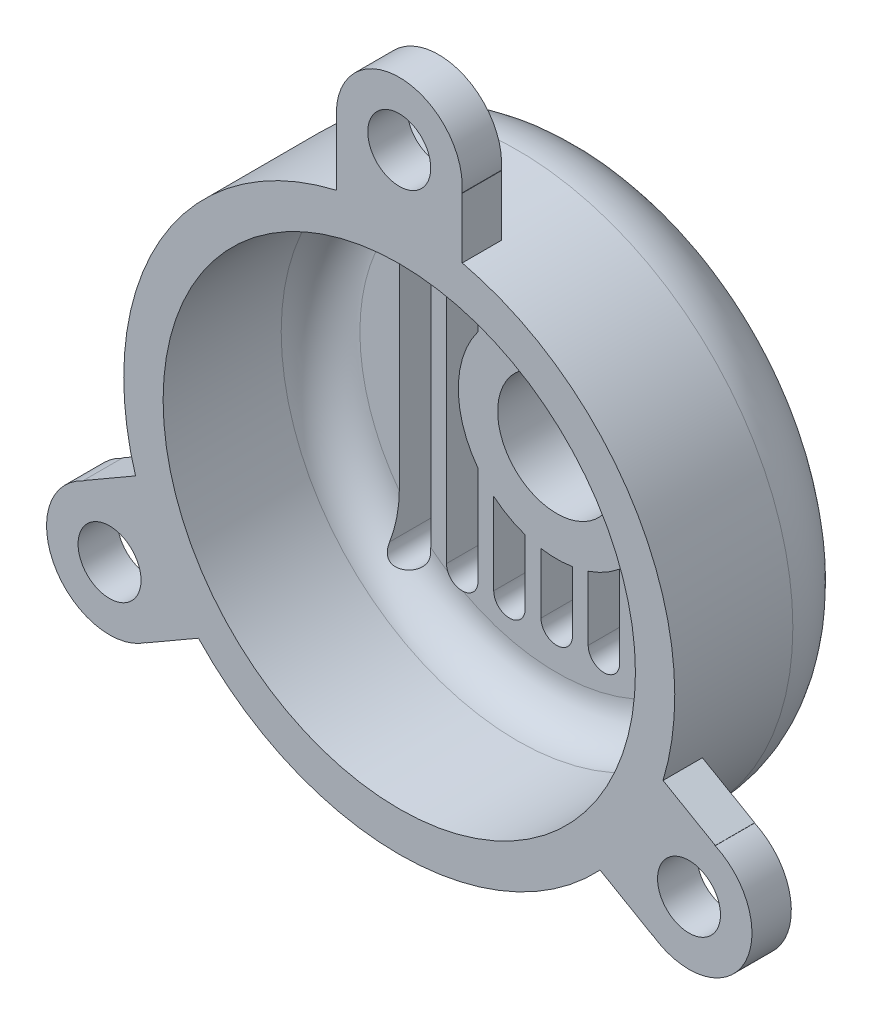
from build123d import *

# Parameters (mm, degrees)
SKETCH3_R           = 4
BOSS_EXTRUDE1_DEPTH = 5
CUT_EXTRUDE1_DEPTH  = 80
SKETCH8_R           = 12.5
SKETCH8_R_2         = 7.5
BOSS_EXTRUDE2_DEPTH = 10
FILLET1_R           = 2
SKETCH9_R           = 7.5
CUT_EXTRUDE2_DEPTH  = 46


with BuildPart() as part:
    # Sketch1 → Revolve1 (revolve)
    with BuildSketch(Plane(origin=(0, 0, 0), x_dir=(1, 0, 0), z_dir=(0, 1, 0)), mode=Mode.PRIVATE) as revolve1_sk:
        with BuildLine():
            Line((0, -5), (25, -5))
            ThreePointArc((25, -5), (28.535533906, -6.464466094), (30, -10))
            Line((30, -10), (30, -25))
            Line((30, -25), (35, -25))
            Line((35, -25), (35, -10))
            ThreePointArc((35, -10), (32.071067812, -2.928932188), (25, 0))
            Line((25, 0), (0, 0))
            Line((0, 0), (0, -5))
        make_face()
    revolve(revolve1_sk.sketch.rotate(Axis((0, 0, -16.961133808), (0, 0, 1)), 180), axis=Axis((0, 0, -16.961133808), (0, 0, 1)))

    # Sketch3 → Boss-Extrude1 (add)
    with BuildSketch(Plane.XY.offset(25)):
        with BuildLine():
            ThreePointArc((-8, 34.073450075), (0, 35), (8, 34.073450075))
            Line((8, 34.073450075), (8, 41.740268327))
            ThreePointArc((8, 41.740268327), (7.982245051, 41.743667351), (7.964488658, 41.747058824))
            ThreePointArc((7.964488658, 41.747058824), (7.991117233, 42.123110935), (8, 42.5))
            ThreePointArc((8, 42.5), (0, 50.5), (-8, 42.5))
            ThreePointArc((-8, 42.5), (-7.991117233, 42.123110935), (-7.964488658, 41.747058824))
            ThreePointArc((-7.964488658, 41.747058824), (-7.982245051, 41.743667351), (-8, 41.740268327))
            Line((-8, 41.740268327), (-8, 34.073450075))
        make_face()
        with Locations((0, 42.5)):
            Circle(SKETCH3_R, mode=Mode.SUBTRACT)
        with BuildLine():
            Line((-32.148132732, -27.798337394), (-25.508473359, -23.964928268))
            ThreePointArc((-25.508473359, -23.964928268), (-30.310889132, -17.5), (-33.508473359, -10.108521807))
            Line((-33.508473359, -10.108521807), (-40.148132732, -13.941930933))
            ThreePointArc((-40.148132732, -13.941930933), (-40.142198899, -13.959006682), (-40.136257804, -13.976079906))
            ThreePointArc((-40.136257804, -13.976079906), (-40.475242772, -14.141044939), (-40.806079661, -14.32179677))
            ThreePointArc((-40.806079661, -14.32179677), (-43.734282891, -25.25), (-32.806079661, -28.17820323))
            ThreePointArc((-32.806079661, -28.17820323), (-32.484125539, -27.982065996), (-32.171769145, -27.770978918))
            ThreePointArc((-32.171769145, -27.770978918), (-32.159953848, -27.784660669), (-32.148132732, -27.798337394))
        make_face()
        with Locations((-36.806079661, -21.25)):
            Circle(SKETCH3_R, mode=Mode.SUBTRACT)
        with BuildLine():
            ThreePointArc((32.806079661, -28.17820323), (43.734282891, -25.25), (40.806079661, -14.32179677))
            ThreePointArc((40.806079661, -14.32179677), (40.475242772, -14.141044939), (40.136257804, -13.976079906))
            ThreePointArc((40.136257804, -13.976079906), (40.142198899, -13.959006682), (40.148132732, -13.941930933))
            Line((40.148132732, -13.941930933), (33.508473359, -10.108521807))
            ThreePointArc((33.508473359, -10.108521807), (30.310889132, -17.5), (25.508473359, -23.964928268))
            Line((25.508473359, -23.964928268), (32.148132732, -27.798337394))
            ThreePointArc((32.148132732, -27.798337394), (32.159953848, -27.784660669), (32.171769145, -27.770978918))
            ThreePointArc((32.171769145, -27.770978918), (32.484125539, -27.982065996), (32.806079661, -28.17820323))
        make_face()
        with Locations((36.806079661, -21.25)):
            Circle(SKETCH3_R, mode=Mode.SUBTRACT)
    extrude(amount=-BOSS_EXTRUDE1_DEPTH)

    # Sketch5 → Cut-Extrude1 (cut)
    with BuildSketch(Plane.XY):
        with BuildLine():
            Line((2, 20), (2, -20))
            ThreePointArc((2, -20), (0, -22), (-2, -20))
            Line((-2, -20), (-2, 20))
            ThreePointArc((-2, 20), (0, 22), (2, 20))
        make_face()
        with BuildLine():
            Line((8, 20), (8, -20))
            ThreePointArc((8, -20), (6, -22), (4, -20))
            Line((4, -20), (4, 20))
            ThreePointArc((4, 20), (6, 22), (8, 20))
        make_face()
        with BuildLine():
            Line((14, 20), (14, -20))
            ThreePointArc((14, -20), (12, -22), (10, -20))
            Line((10, -20), (10, 20))
            ThreePointArc((10, 20), (12, 22), (14, 20))
        make_face()
        with BuildLine():
            Line((20, 20), (20, -20))
            ThreePointArc((20, -20), (18, -22), (16, -20))
            Line((16, -20), (16, 20))
            ThreePointArc((16, 20), (18, 22), (20, 20))
        make_face()
        with BuildLine():
            Line((-14, 20), (-14, -20))
            ThreePointArc((-14, -20), (-12, -22), (-10, -20))
            Line((-10, -20), (-10, 20))
            ThreePointArc((-10, 20), (-12, 22), (-14, 20))
        make_face()
        with BuildLine():
            Line((-8, 20), (-8, -20))
            ThreePointArc((-8, -20), (-6, -22), (-4, -20))
            Line((-4, -20), (-4, 20))
            ThreePointArc((-4, 20), (-6, 22), (-8, 20))
        make_face()
        with BuildLine():
            Line((-20, 20), (-20, -20))
            ThreePointArc((-20, -20), (-18, -22), (-16, -20))
            Line((-16, -20), (-16, 20))
            ThreePointArc((-16, 20), (-18, 22), (-20, 20))
        make_face()
    extrude(amount=CUT_EXTRUDE1_DEPTH, mode=Mode.SUBTRACT)

    # Sketch8 → Boss-Extrude2 (add)
    with BuildSketch(Plane.XY.offset(5)):
        Circle(SKETCH8_R)
        Circle(SKETCH8_R_2, mode=Mode.SUBTRACT)
    extrude(amount=-BOSS_EXTRUDE2_DEPTH)

    # Fillet1
    fillet1_edges = [part.edges().sort_by_distance(p)[0] for p in [
        (-12.5, 0, -5),
    ]]
    fillet(fillet1_edges, radius=FILLET1_R)

    # Sketch9 → Cut-Extrude2 (cut)
    with BuildSketch(Plane.XY):
        Circle(SKETCH9_R)
    extrude(amount=CUT_EXTRUDE2_DEPTH, mode=Mode.SUBTRACT)


solid = part.part
